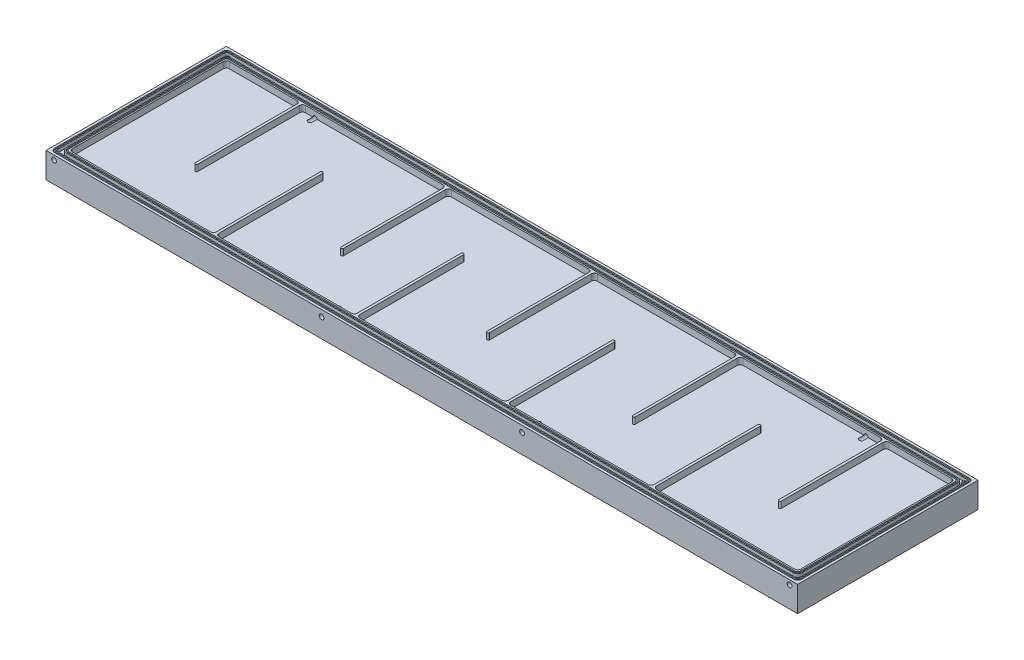
from build123d import *

# Parameters (mm, degrees)
SKETCH1_W           = 1500
SKETCH1_H           = 360
BOSS_EXTRUDE1_DEPTH = 50.8
CUT_EXTRUDE2_DEPTH  = 2.41
CUT_EXTRUDE3_DEPTH  = 2.41
CUT_EXTRUDE4_DEPTH  = 6.35
CUT_EXTRUDE5_DEPTH  = 12.7


with BuildPart() as part:
    # Sketch1 → Boss-Extrude1 (new body)
    with BuildSketch(Plane(origin=(0, 0, 0), x_dir=(1, 0, 0), z_dir=(0, 1, 0))):
        with Locations((750, 180)):
            Rectangle(SKETCH1_W, SKETCH1_H)
    extrude(amount=BOSS_EXTRUDE1_DEPTH)

    # Sketch2_6 → Cut-Extrude2 (cut)
    with BuildSketch(Plane(origin=(0, 50.8, 0), x_dir=(1, 0, 0), z_dir=(0, 1, 0))):
        with BuildLine():
            ThreePointArc((1474.68, 342.34), (1480.096437944, 340.096437944), (1482.34, 334.68))
            Line((1482.34, 334.68), (1482.34, 25.32))
            ThreePointArc((1482.34, 25.32), (1480.096437944, 19.903562056), (1474.68, 17.66))
            Line((1474.68, 17.66), (25.32, 17.66))
            ThreePointArc((25.32, 17.66), (19.903562056, 19.903562056), (17.66, 25.32))
            Line((17.66, 25.32), (17.66, 334.68))
            ThreePointArc((17.66, 334.68), (19.903562056, 340.096437944), (25.32, 342.34))
            Line((25.32, 342.34), (1474.68, 342.34))
        make_face()
        with BuildLine():
            Line((1474.58, 339.58), (25.42, 339.58))
            ThreePointArc((25.42, 339.58), (21.884466094, 338.115533906), (20.42, 334.58))
            Line((20.42, 334.58), (20.42, 25.42))
            ThreePointArc((20.42, 25.42), (21.884466094, 21.884466094), (25.42, 20.42))
            Line((25.42, 20.42), (1474.58, 20.42))
            ThreePointArc((1474.58, 20.42), (1478.115533906, 21.884466094), (1479.58, 25.42))
            Line((1479.58, 25.42), (1479.58, 334.58))
            ThreePointArc((1479.58, 334.58), (1478.115533906, 338.115533906), (1474.58, 339.58))
        make_face(mode=Mode.SUBTRACT)
    extrude(amount=-CUT_EXTRUDE2_DEPTH, mode=Mode.SUBTRACT)

    # Sketch2_7 → Cut-Extrude3 (cut)
    with BuildSketch(Plane(origin=(0, 50.8, 0), x_dir=(1, 0, 0), z_dir=(0, 1, 0))):
        with BuildLine():
            Line((1495.1, 12.56), (1495.1, 347.44))
            ThreePointArc((1495.1, 347.44), (1492.856437944, 352.856437944), (1487.44, 355.1))
            Line((1487.44, 355.1), (12.56, 355.1))
            ThreePointArc((12.56, 355.1), (7.143562056, 352.856437944), (4.9, 347.44))
            Line((4.9, 347.44), (4.9, 12.56))
            ThreePointArc((4.9, 12.56), (7.143562056, 7.143562056), (12.56, 4.9))
            Line((12.56, 4.9), (1487.44, 4.9))
            ThreePointArc((1487.44, 4.9), (1492.856437944, 7.143562056), (1495.1, 12.56))
        make_face()
        with BuildLine():
            Line((1487.34, 352.34), (12.66, 352.34))
            ThreePointArc((12.66, 352.34), (9.124466094, 350.875533906), (7.66, 347.34))
            Line((7.66, 347.34), (7.66, 12.66))
            ThreePointArc((7.66, 12.66), (9.124466094, 9.124466094), (12.66, 7.66))
            Line((12.66, 7.66), (1487.34, 7.66))
            ThreePointArc((1487.34, 7.66), (1490.875533906, 9.124466094), (1492.34, 12.66))
            Line((1492.34, 12.66), (1492.34, 347.34))
            ThreePointArc((1492.34, 347.34), (1490.875533906, 350.875533906), (1487.34, 352.34))
        make_face(mode=Mode.SUBTRACT)
    extrude(amount=-CUT_EXTRUDE3_DEPTH, mode=Mode.SUBTRACT)

    # Sketch2 → Cut-Extrude4 (cut)
    with BuildSketch(Plane(origin=(0, 50.8, 0), x_dir=(1, 0, 0), z_dir=(0, 1, 0))):
        with BuildLine():
            Line((1490.34, 12.66), (1490.34, 347.34))
            ThreePointArc((1490.34, 347.34), (1489.461320344, 349.461320344), (1487.34, 350.34))
            Line((1487.34, 350.34), (12.66, 350.34))
            ThreePointArc((12.66, 350.34), (10.538679656, 349.461320344), (9.66, 347.34))
            Line((9.66, 347.34), (9.66, 12.66))
            ThreePointArc((9.66, 12.66), (10.538679656, 10.538679656), (12.66, 9.66))
            Line((12.66, 9.66), (1487.34, 9.66))
            ThreePointArc((1487.34, 9.66), (1489.461320344, 10.538679656), (1490.34, 12.66))
        make_face()
        with BuildLine():
            Line((1474.68, 344.34), (25.32, 344.34))
            ThreePointArc((25.32, 344.34), (18.489348494, 341.510651506), (15.66, 334.68))
            Line((15.66, 334.68), (15.66, 25.32))
            ThreePointArc((15.66, 25.32), (18.489348494, 18.489348494), (25.32, 15.66))
            Line((25.32, 15.66), (1474.68, 15.66))
            ThreePointArc((1474.68, 15.66), (1481.510651506, 18.489348494), (1484.34, 25.32))
            Line((1484.34, 25.32), (1484.34, 334.68))
            ThreePointArc((1484.34, 334.68), (1481.510651506, 341.510651506), (1474.68, 344.34))
        make_face(mode=Mode.SUBTRACT)
    extrude(amount=-CUT_EXTRUDE4_DEPTH, mode=Mode.SUBTRACT)

    # Sketch2_10 → Cut-Extrude5 (cut)
    with BuildSketch(Plane(origin=(0, 50.8, 0), x_dir=(1, 0, 0), z_dir=(0, 1, 0))):
        with BuildLine():
            Line((164.2, 336.68), (29.32, 336.68))
            ThreePointArc((29.32, 336.68), (25.077359313, 334.922640687), (23.32, 330.68))
            Line((23.32, 330.68), (23.32, 29.32))
            ThreePointArc((23.32, 29.32), (25.077359313, 25.077359313), (29.32, 23.32))
            Line((29.32, 23.32), (304.76, 23.32))
            ThreePointArc((304.76, 23.32), (309.002640687, 25.077359313), (310.76, 29.32))
            Line((310.76, 29.32), (310.76, 236.414561591))
            ThreePointArc((310.76, 236.414561591), (313.26, 238.914561591), (315.76, 236.414561591))
            Line((315.76, 236.414561591), (315.76, 29.32))
            ThreePointArc((315.76, 29.32), (317.517359313, 25.077359313), (321.76, 23.32))
            Line((321.76, 23.32), (585.88, 23.32))
            ThreePointArc((585.88, 23.32), (590.122640687, 25.077359313), (591.88, 29.32))
            Line((591.88, 29.32), (591.88, 236.414561591))
            ThreePointArc((591.88, 236.414561591), (594.38, 238.914561591), (596.88, 236.414561591))
            Line((596.88, 236.414561591), (596.88, 29.32))
            ThreePointArc((596.88, 29.32), (598.637359313, 25.077359313), (602.88, 23.32))
            Line((602.88, 23.32), (887.08, 23.32))
            ThreePointArc((887.08, 23.32), (891.322640687, 25.077359313), (893.08, 29.32))
            Line((893.08, 29.32), (893.08, 236.414561591))
            ThreePointArc((893.08, 236.414561591), (895.58, 238.914561591), (898.08, 236.414561591))
            Line((898.08, 236.414561591), (898.08, 29.32))
            ThreePointArc((898.08, 29.32), (899.837359313, 25.077359313), (904.08, 23.32))
            Line((904.08, 23.32), (1178.24, 23.32))
            ThreePointArc((1178.24, 23.32), (1182.482640687, 25.077359313), (1184.24, 29.32))
            Line((1184.24, 29.32), (1184.24, 236.414561591))
            ThreePointArc((1184.24, 236.414561591), (1186.74, 238.914561591), (1189.24, 236.414561591))
            Line((1189.24, 236.414561591), (1189.24, 29.32))
            ThreePointArc((1189.24, 29.32), (1190.997359313, 25.077359313), (1195.24, 23.32))
            Line((1195.24, 23.32), (1470.68, 23.32))
            ThreePointArc((1470.68, 23.32), (1474.922640687, 25.077359313), (1476.68, 29.32))
            Line((1476.68, 29.32), (1476.68, 330.68))
            ThreePointArc((1476.68, 330.68), (1474.922640687, 334.922640687), (1470.68, 336.68))
            Line((1470.68, 336.68), (1345.84, 336.68))
            ThreePointArc((1345.84, 336.68), (1341.597359313, 334.922640687), (1339.84, 330.68))
            Line((1339.84, 330.68), (1339.84, 127.77))
            ThreePointArc((1339.84, 127.77), (1337.34, 125.27), (1334.84, 127.77))
            Line((1334.84, 127.77), (1334.84, 330.68))
            ThreePointArc((1334.84, 330.68), (1333.082640687, 334.922640687), (1328.84, 336.68))
            Line((1328.84, 336.68), (1054.68, 336.68))
            ThreePointArc((1054.68, 336.68), (1050.437359313, 334.922640687), (1048.68, 330.68))
            Line((1048.68, 330.68), (1048.68, 127.77))
            ThreePointArc((1048.68, 127.77), (1046.18, 125.27), (1043.68, 127.77))
            Line((1043.68, 127.77), (1043.68, 330.68))
            ThreePointArc((1043.68, 330.68), (1041.922640687, 334.922640687), (1037.68, 336.68))
            Line((1037.68, 336.68), (763.52, 336.68))
            ThreePointArc((763.52, 336.68), (759.277359313, 334.922640687), (757.52, 330.68))
            Line((757.52, 330.68), (757.52, 127.77))
            ThreePointArc((757.52, 127.77), (755.02, 125.27), (752.52, 127.77))
            Line((752.52, 127.77), (752.52, 330.68))
            ThreePointArc((752.52, 330.68), (750.762640687, 334.922640687), (746.52, 336.68))
            Line((746.52, 336.68), (472.36, 336.68))
            ThreePointArc((472.36, 336.68), (468.117359313, 334.922640687), (466.36, 330.68))
            Line((466.36, 330.68), (466.36, 127.77))
            ThreePointArc((466.36, 127.77), (463.86, 125.27), (461.36, 127.77))
            Line((461.36, 127.77), (461.36, 330.68))
            ThreePointArc((461.36, 330.68), (459.602640687, 334.922640687), (455.36, 336.68))
            Line((455.36, 336.68), (181.2, 336.68))
            ThreePointArc((181.2, 336.68), (176.957359313, 334.922640687), (175.2, 330.68))
            Line((175.2, 330.68), (175.2, 127.77))
            ThreePointArc((175.2, 127.77), (172.7, 125.27), (170.2, 127.77))
            Line((170.2, 127.77), (170.2, 330.68))
            ThreePointArc((170.2, 330.68), (168.442640687, 334.922640687), (164.2, 336.68))
        make_face()
    extrude(amount=-CUT_EXTRUDE5_DEPTH, mode=Mode.SUBTRACT)

    # Sketch18 → 1_8 NPT Tapped Hole2 (revolve, cut)
    with BuildSketch(Plane(origin=(16, 42, 0), x_dir=(0, -1, 0), z_dir=(1, 0, 0))):
        Polygon((0, 0), (0, 17.533468714), (4.2164, 15), (4.2164, 6.92), (4.537398933, 6.92), (4.744593, 0), align=None)
    revolve(axis=Axis((16, 42, 6.35), (0, 0, -1)), mode=Mode.SUBTRACT)

    # Sketch20 → 1_8 NPT Tapped Hole3 (revolve, cut)
    with BuildSketch(Plane(origin=(1484, 42, -360), x_dir=(0, 1, 0), z_dir=(1, 0, 0))):
        Polygon((0, 0), (0, 17.533468714), (4.2164, 15), (4.2164, 6.92), (4.537398933, 6.92), (4.744593, 0), align=None)
    revolve(axis=Axis((1484, 42, -366.35), (0, 0, 1)), mode=Mode.SUBTRACT)

    # Sketch22 → 1_8 NPT Tapped Hole4 (revolve, cut)
    with BuildSketch(Plane(origin=(1484, 42, 0), x_dir=(0, -1, 0), z_dir=(1, 0, 0))):
        Polygon((0, 0), (0, 17.533468714), (4.2164, 15), (4.2164, 6.92), (4.537398933, 6.92), (4.744593, 0), align=None)
    revolve(axis=Axis((1484, 42, 6.35), (0, 0, -1)), mode=Mode.SUBTRACT)

    # Sketch24 → 1_8 NPT Tapped Hole5 (revolve, cut)
    with BuildSketch(Plane(origin=(16, 42, -360), x_dir=(0, 1, 0), z_dir=(1, 0, 0))):
        Polygon((0, 0), (0, 17.533468714), (4.2164, 15), (4.2164, 6.92), (4.537398933, 6.92), (4.744593, 0), align=None)
    revolve(axis=Axis((16, 42, -366.35), (0, 0, 1)), mode=Mode.SUBTRACT)

    # Sketch26 → 1_8 NPT Tapped Hole6 (revolve, cut)
    with BuildSketch(Plane(origin=(550, 38.1, 0), x_dir=(0, -1, 0), z_dir=(1, 0, 0))):
        Polygon((0, 0), (0, 37.533468714), (4.2164, 35), (4.2164, 6.92), (4.537398933, 6.92), (4.744593, 0), align=None)
    revolve(axis=Axis((550, 38.1, 6.35), (0, 0, -1)), mode=Mode.SUBTRACT)

    # Sketch28 → 1_8 NPT Tapped Hole7 (revolve, cut)
    with BuildSketch(Plane(origin=(950, 38.1, 0), x_dir=(0, -1, 0), z_dir=(1, 0, 0))):
        Polygon((0, 0), (0, 37.533468714), (4.2164, 35), (4.2164, 6.92), (4.537398933, 6.92), (4.744593, 0), align=None)
    revolve(axis=Axis((950, 38.1, 6.35), (0, 0, -1)), mode=Mode.SUBTRACT)

    # Sketch30 → 1_8 NPT Tapped Hole8 (revolve, cut)
    with BuildSketch(Plane(origin=(1300, 38.1, -360), x_dir=(0, 1, 0), z_dir=(1, 0, 0))):
        Polygon((0, 0), (0, 37.533468714), (4.2164, 35), (4.2164, 6.92), (4.537398933, 6.92), (4.744593, 0), align=None)
    revolve(axis=Axis((1300, 38.1, -366.35), (0, 0, 1)), mode=Mode.SUBTRACT)

    # Sketch32 → 1_8 NPT Tapped Hole9 (revolve, cut)
    with BuildSketch(Plane(origin=(200, 38.1, -360), x_dir=(0, 1, 0), z_dir=(1, 0, 0))):
        Polygon((0, 0), (0, 37.533468714), (4.2164, 35), (4.2164, 6.92), (4.537398933, 6.92), (4.744593, 0), align=None)
    revolve(axis=Axis((200, 38.1, -366.35), (0, 0, 1)), mode=Mode.SUBTRACT)

    # Sketch34 → Hole1 (revolve, cut)
    with BuildSketch(Plane(origin=(27.12, 38.1, -27.75), x_dir=(0, 0, 1), z_dir=(1, 0, 0))):
        Polygon((0, 0), (0, 38.1), (0.795, 38.1), (0.795, 30.952364081), (2.38, 30), (2.38, 0), align=None)
    revolve(axis=Axis((27.12, 44.230023899, -27.75), (0, -1, 0)), mode=Mode.SUBTRACT)


solid = part.part
